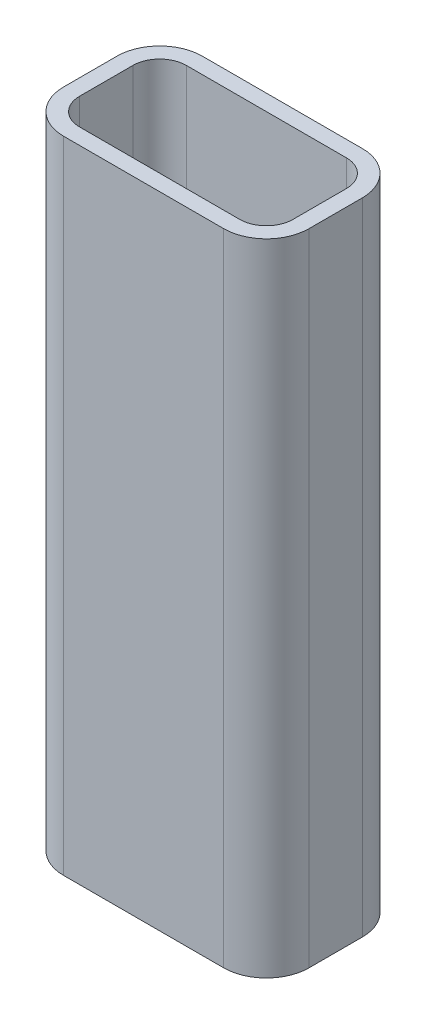
from build123d import *

# Parameters (mm, degrees)
EXTRUDE_THIN1_DEPTH = 60


with BuildPart() as part:
    # Sketch1 → Extrude-Thin1 (new body, symmetric)
    with BuildSketch(Plane(origin=(0, 0, 0), x_dir=(1, 0, 0), z_dir=(0, 1, 0))):
        with BuildLine():
            Line((15, -13), (-15, -13))
            ThreePointArc((-15, -13), (-20.656854249, -10.656854249), (-23, -5))
            Line((-23, -5), (-23, 5))
            ThreePointArc((-23, 5), (-20.656854249, 10.656854249), (-15, 13))
            Line((-15, 13), (15, 13))
            ThreePointArc((15, 13), (20.656854249, 10.656854249), (23, 5))
            Line((23, 5), (23, -5))
            ThreePointArc((23, -5), (20.656854249, -10.656854249), (15, -13))
        make_face()
        with BuildLine():
            Line((15, -10), (-15, -10))
            ThreePointArc((-15, -10), (-18.535533906, -8.535533906), (-20, -5))
            Line((-20, -5), (-20, 5))
            ThreePointArc((-20, 5), (-18.535533906, 8.535533906), (-15, 10))
            Line((-15, 10), (15, 10))
            ThreePointArc((15, 10), (18.535533906, 8.535533906), (20, 5))
            Line((20, 5), (20, -5))
            ThreePointArc((20, -5), (18.535533906, -8.535533906), (15, -10))
        make_face(mode=Mode.SUBTRACT)
    extrude(amount=EXTRUDE_THIN1_DEPTH, both=True)


solid = part.part
